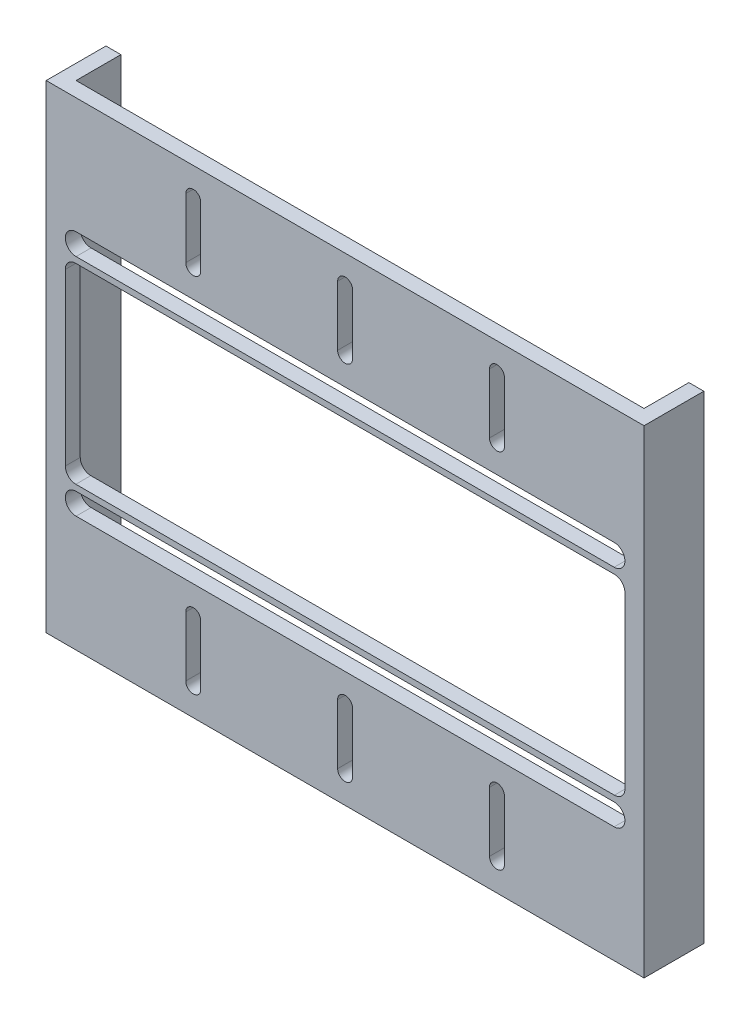
from build123d import *

# Parameters (mm, degrees)
BOSS_EXTRUDE1_DEPTH     = 139.7
SKETCH3_W               = 118.872
SKETCH3_H               = 40.64
SKETCH3_W_2             = 127
SKETCH3_H_2             = 38.1
CUT_EXTRUDE1_DEPTH      = 10.525
CUT_EXTRUDE1_DEPTH_BACK = 4.175
FILLET1_R               = 2.2352
CUT_EXTRUDE2_DEPTH      = 13.7


with BuildPart() as part:
    # Sketch2 → Boss-Extrude1 (new body)
    with BuildSketch(Plane(origin=(0, 0, 0), x_dir=(1, 0, 0), z_dir=(0, 1, 0))):
        Polygon((0, 0), (0, 12.7), (3.175, 12.7), (3.175, 3.175), (123.825, 3.175), (123.825, 12.7), (127, 12.7), (127, 0), align=None)
    extrude(amount=BOSS_EXTRUDE1_DEPTH)

    # Sketch3 → Cut-Extrude1 (cut, two sides)
    with BuildSketch(Plane(origin=(0, 0, -3.175), x_dir=(-1, 0, 0), z_dir=(0, 0, -1))) as cut_extrude1_sk:
        with BuildLine():
            Line((-6.35, 110.49), (-120.65, 110.49))
            ThreePointArc((-120.65, 110.49), (-122.936, 112.776), (-120.65, 115.062))
            Line((-120.65, 115.062), (-6.35, 115.062))
            ThreePointArc((-6.35, 115.062), (-4.064, 112.776), (-6.35, 110.49))
        make_face()
        with BuildLine():
            Line((-6.35, 62.738), (-120.65, 62.738))
            ThreePointArc((-120.65, 62.738), (-122.936, 65.024), (-120.65, 67.31))
            Line((-120.65, 67.31), (-6.35, 67.31))
            ThreePointArc((-6.35, 67.31), (-4.064, 65.024), (-6.35, 62.738))
        make_face()
        with Locations((-63.5, 88.9)):
            Rectangle(SKETCH3_W, SKETCH3_H)
        with Locations((-63.5, 19.05)):
            Rectangle(SKETCH3_W_2, SKETCH3_H_2)
    extrude(amount=CUT_EXTRUDE1_DEPTH, mode=Mode.SUBTRACT)
    extrude(cut_extrude1_sk.sketch, amount=-CUT_EXTRUDE1_DEPTH_BACK, mode=Mode.SUBTRACT)

    # Fillet1
    fillet1_edges = [part.edges().sort_by_distance(p)[0] for p in [
        (4.064, 68.58, -1.5875),
        (122.936, 68.58, -1.5875),
        (122.936, 109.22, -1.5875),
        (4.064, 109.22, -1.5875),
    ]]
    fillet(fillet1_edges, radius=FILLET1_R)

    # Sketch4 → Cut-Extrude2 (cut, through all)
    with BuildSketch(Plane.XY):
        with BuildLine():
            Line((32.8295, 133.731), (32.8295, 121.031))
            ThreePointArc((32.8295, 121.031), (31.242, 119.4435), (29.6545, 121.031))
            Line((29.6545, 121.031), (29.6545, 133.731))
            ThreePointArc((29.6545, 133.731), (31.242, 135.3185), (32.8295, 133.731))
        make_face()
        with BuildLine():
            Line((32.8295, 56.769), (32.8295, 44.069))
            ThreePointArc((32.8295, 44.069), (31.242, 42.4815), (29.6545, 44.069))
            Line((29.6545, 44.069), (29.6545, 56.769))
            ThreePointArc((29.6545, 56.769), (31.242, 58.3565), (32.8295, 56.769))
        make_face()
        with BuildLine():
            Line((61.9125, 133.731), (61.9125, 121.031))
            ThreePointArc((61.9125, 121.031), (63.5, 119.4435), (65.0875, 121.031))
            Line((65.0875, 121.031), (65.0875, 133.731))
            ThreePointArc((65.0875, 133.731), (63.5, 135.3185), (61.9125, 133.731))
        make_face()
        with BuildLine():
            Line((61.9125, 56.769), (61.9125, 44.069))
            ThreePointArc((61.9125, 44.069), (63.5, 42.4815), (65.0875, 44.069))
            Line((65.0875, 44.069), (65.0875, 56.769))
            ThreePointArc((65.0875, 56.769), (63.5, 58.3565), (61.9125, 56.769))
        make_face()
        with BuildLine():
            Line((94.1705, 133.731), (94.1705, 121.031))
            ThreePointArc((94.1705, 121.031), (95.758, 119.4435), (97.3455, 121.031))
            Line((97.3455, 121.031), (97.3455, 133.731))
            ThreePointArc((97.3455, 133.731), (95.758, 135.3185), (94.1705, 133.731))
        make_face()
        with BuildLine():
            Line((94.1705, 56.769), (94.1705, 44.069))
            ThreePointArc((94.1705, 44.069), (95.758, 42.4815), (97.3455, 44.069))
            Line((97.3455, 44.069), (97.3455, 56.769))
            ThreePointArc((97.3455, 56.769), (95.758, 58.3565), (94.1705, 56.769))
        make_face()
    extrude(amount=-CUT_EXTRUDE2_DEPTH, mode=Mode.SUBTRACT)


solid = part.part
